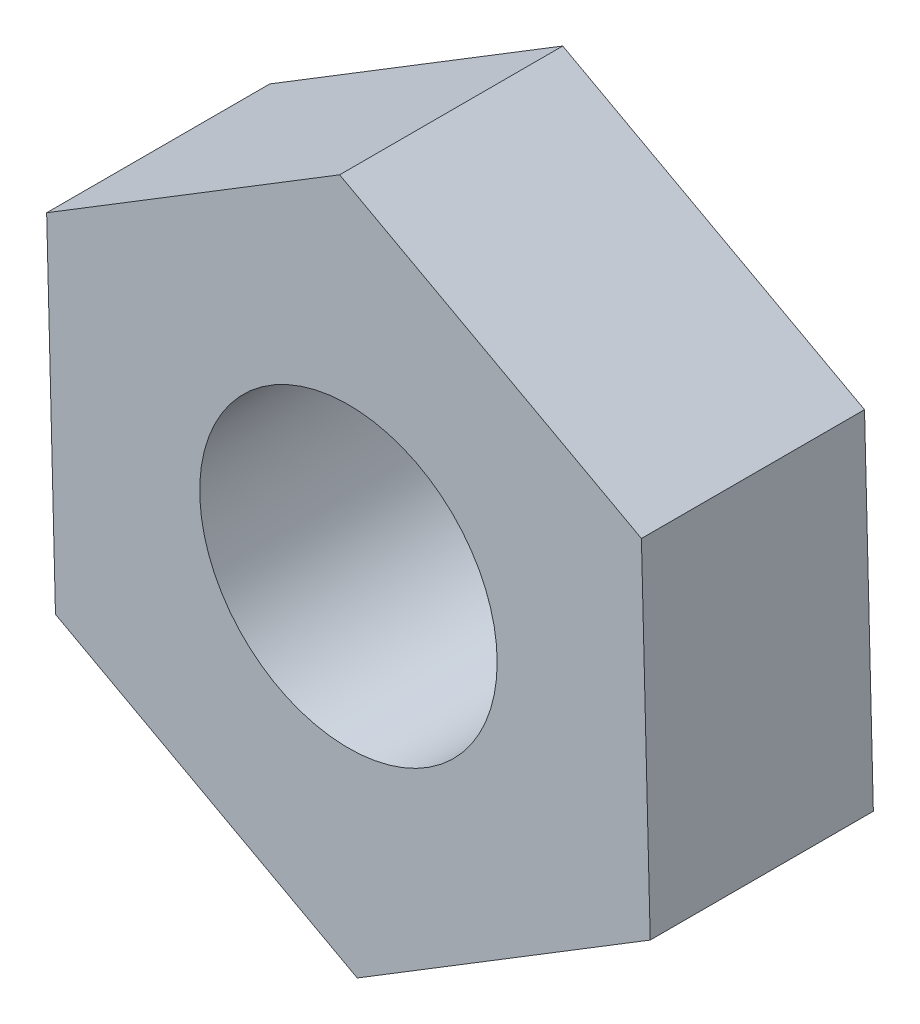
from build123d import *

# Parameters (mm, degrees)
EXTRUDE_1_DEPTH     = 1.5
SKETCH_2_R          = 1
CUT_EXTRUDE_1_DEPTH = 2


with BuildPart() as part:
    # 草图1 → 凸台-拉伸1 (new body)
    with BuildSketch(Plane.XY):
        Polygon((2.028972176, -1.102998297), (1.969710633, 1.205642299), (-0.059261542, 2.308640596), (-2.028972176, 1.102998297), (-1.969710633, -1.205642299), (0.059261542, -2.308640596), align=None)
    extrude(amount=EXTRUDE_1_DEPTH)

    # 草图2 → 切除-拉伸1 (cut)
    with BuildSketch(Plane.XY.offset(1.5)):
        Circle(SKETCH_2_R)
    extrude(amount=-CUT_EXTRUDE_1_DEPTH, mode=Mode.SUBTRACT)


solid = part.part
